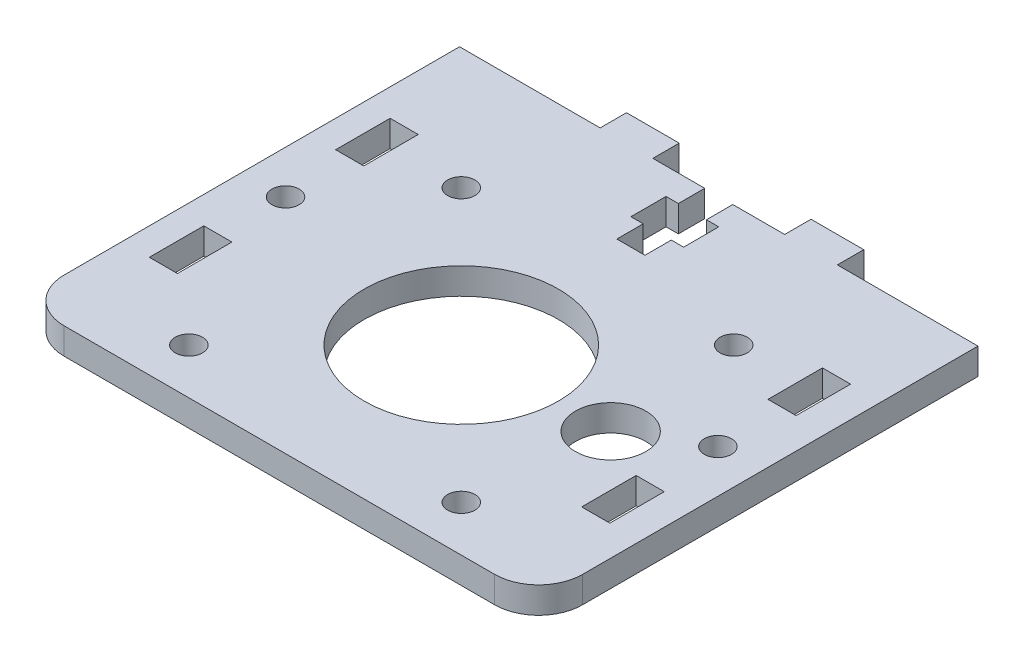
from build123d import *

# Parameters (mm, degrees)
CROQUIS1_R              = 1.55
CROQUIS1_R_2            = 11.05
CROQUIS1_R_3            = 4
CROQUIS1_W              = 3.2
CROQUIS1_H              = 6.2
SALIENTE_EXTRUIR1_DEPTH = 3


with BuildPart() as part:
    # Croquis1 → Saliente-Extruir1 (new body)
    with BuildSketch(Plane(origin=(0, 0, 0), x_dir=(1, 0, 0), z_dir=(0, 1, 0))):
        with BuildLine():
            Line((5, 0), (54, 0))
            ThreePointArc((54, 0), (57.535533906, 1.464466094), (59, 5))
            Line((59, 5), (59, 50))
            Line((59, 50), (43, 50))
            Line((43, 50), (43, 53))
            Line((43, 53), (37, 53))
            Line((37, 53), (37, 50))
            Line((37, 50), (31.1, 50))
            Line((31.1, 50), (31.1, 47))
            Line((31.1, 47), (32.5, 47))
            Line((32.5, 47), (32.5, 43))
            Line((32.5, 43), (31.1, 43))
            Line((31.1, 43), (31.1, 40))
            Line((31.1, 40), (27.9, 40))
            Line((27.9, 40), (27.9, 43))
            Line((27.9, 43), (26.5, 43))
            Line((26.5, 43), (26.5, 47))
            Line((26.5, 47), (27.9, 47))
            Line((27.9, 47), (27.9, 50))
            Line((27.9, 50), (22, 50))
            Line((22, 50), (22, 53))
            Line((22, 53), (16, 53))
            Line((16, 53), (16, 50))
            Line((16, 50), (0, 50))
            Line((0, 50), (0, 5))
            ThreePointArc((0, 5), (1.464466094, 1.464466094), (5, 0))
        make_face()
        with Locations((4.9, 25.3)):
            Circle(CROQUIS1_R, mode=Mode.SUBTRACT)
        with Locations((29.5, 20.7)):
            Circle(CROQUIS1_R_2, mode=Mode.SUBTRACT)
        with Locations((14, 36.2)):
            Circle(CROQUIS1_R, mode=Mode.SUBTRACT)
        with Locations((45, 36.2)):
            Circle(CROQUIS1_R, mode=Mode.SUBTRACT)
        with Locations((45, 5.2)):
            Circle(CROQUIS1_R, mode=Mode.SUBTRACT)
        with Locations((14, 5.2)):
            Circle(CROQUIS1_R, mode=Mode.SUBTRACT)
        with Locations((46.5, 20.7)):
            Circle(CROQUIS1_R_3, mode=Mode.SUBTRACT)
        with Locations((54.1, 25.3)):
            Circle(CROQUIS1_R, mode=Mode.SUBTRACT)
        with Locations((4.7, 14.7)):
            Rectangle(CROQUIS1_W, CROQUIS1_H, mode=Mode.SUBTRACT)
        with Locations((4.7, 35.9)):
            Rectangle(CROQUIS1_W, CROQUIS1_H, mode=Mode.SUBTRACT)
        with Locations((53.9, 35.9)):
            Rectangle(CROQUIS1_W, CROQUIS1_H, mode=Mode.SUBTRACT)
        with Locations((53.9, 14.7)):
            Rectangle(CROQUIS1_W, CROQUIS1_H, mode=Mode.SUBTRACT)
    extrude(amount=SALIENTE_EXTRUIR1_DEPTH)


solid = part.part
